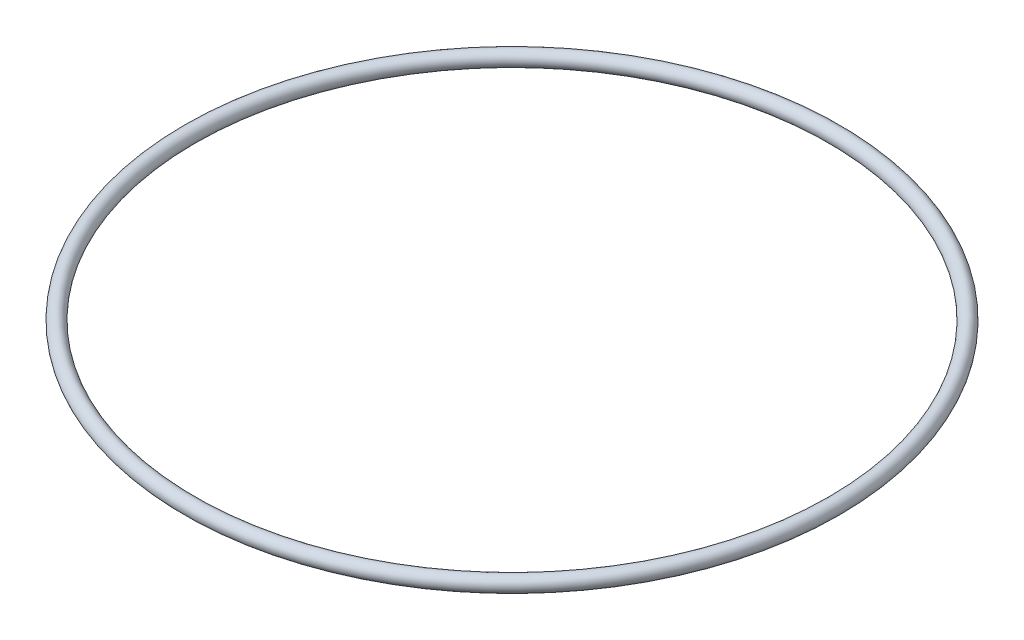
from build123d import *

# Parameters (mm, degrees)
SKETCH2_R = 1.3


with BuildPart() as part:
    # Sweep1: sweep along a path in Sketch1
    with BuildLine(Plane(origin=(0, 0, 0), x_dir=(1, 0, 0), z_dir=(0, 1, 0))) as sweep1_path:
        CenterArc((0, 0), 56.3, 0, 360)
    # Sketch2 → Sweep1 (sweep)
    with BuildSketch(Plane.XY):
        with Locations((-56.3, 0)):
            Circle(SKETCH2_R)
    sweep(path=sweep1_path.line)


solid = part.part
